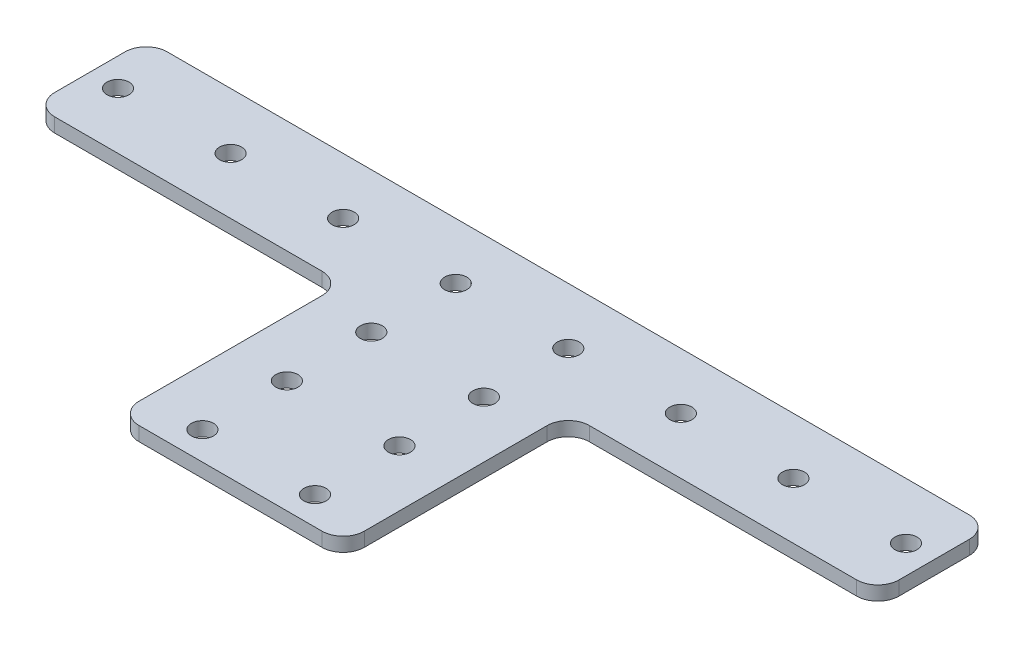
from build123d import *

# Parameters (mm, degrees)
SKETCH1_W           = 190.5
SKETCH1_H           = 25.4
SKETCH1_R           = 2.4892
SKETCH1_W_2         = 50.8
SKETCH1_H_2         = 50.8
BOSS_EXTRUDE1_DEPTH = 3.175
FILLET1_R           = 4.7625


with BuildPart() as part:
    # Sketch1 → Boss-Extrude1 (new body)
    with BuildSketch(Plane(origin=(0, 0, 0), x_dir=(1, 0, 0), z_dir=(0, 1, 0))):
        with Locations((95.25, 12.7)):
            Rectangle(SKETCH1_W, SKETCH1_H)
        with Locations((6.35, 12.7)):
            Circle(SKETCH1_R, mode=Mode.SUBTRACT)
        with Locations((31.75, 12.7)):
            Circle(SKETCH1_R, mode=Mode.SUBTRACT)
        with Locations((57.15, 12.7)):
            Circle(SKETCH1_R, mode=Mode.SUBTRACT)
        with Locations((82.55, 12.7)):
            Circle(SKETCH1_R, mode=Mode.SUBTRACT)
        with Locations((107.95, 12.7)):
            Circle(SKETCH1_R, mode=Mode.SUBTRACT)
        with Locations((133.35, 12.7)):
            Circle(SKETCH1_R, mode=Mode.SUBTRACT)
        with Locations((158.75, 12.7)):
            Circle(SKETCH1_R, mode=Mode.SUBTRACT)
        with Locations((184.15, 12.7)):
            Circle(SKETCH1_R, mode=Mode.SUBTRACT)
        with Locations((95.25, -25.4)):
            Rectangle(SKETCH1_W_2, SKETCH1_H_2)
        with Locations((82.55, -6.35)):
            Circle(SKETCH1_R, mode=Mode.SUBTRACT)
        with Locations((107.95, -6.35)):
            Circle(SKETCH1_R, mode=Mode.SUBTRACT)
        with Locations((107.95, -25.4)):
            Circle(SKETCH1_R, mode=Mode.SUBTRACT)
        with Locations((107.95, -44.45)):
            Circle(SKETCH1_R, mode=Mode.SUBTRACT)
        with Locations((82.55, -25.4)):
            Circle(SKETCH1_R, mode=Mode.SUBTRACT)
        with Locations((82.55, -44.45)):
            Circle(SKETCH1_R, mode=Mode.SUBTRACT)
    extrude(amount=BOSS_EXTRUDE1_DEPTH)

    # Fillet1
    fillet1_edges = [part.edges().sort_by_distance(p)[0] for p in [
        (120.65, 1.5875, 50.8),
        (69.85, 1.5875, 50.8),
        (69.85, 1.5875, 0),
        (0, 1.5875, 0),
        (0, 1.5875, -25.4),
        (190.5, 1.5875, -25.4),
        (190.5, 1.5875, 0),
        (120.65, 1.5875, 0),
    ]]
    fillet(fillet1_edges, radius=FILLET1_R)


solid = part.part
